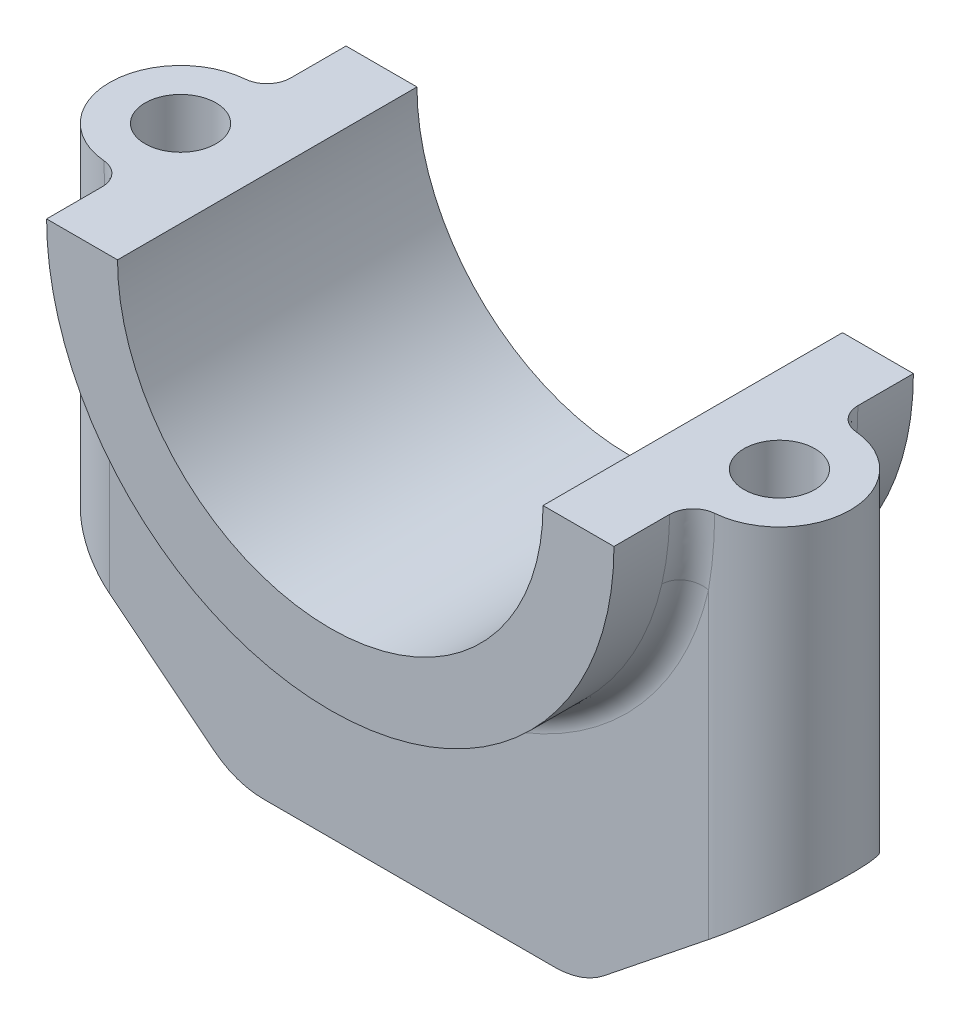
from build123d import *

# Parameters (mm, degrees)
BOSS_EXTRUDE3_DEPTH = 19
BOSS_EXTRUDE4_DEPTH = 60
CUT_EXTRUDE3_REACH  = 30
CUT_EXTRUDE4_REACH  = 62
SKETCH11_R          = 4.5
CUT_EXTRUDE5_DEPTH  = 23
FILLET2_R           = 10
FILLET3_R           = 3


with BuildPart() as part:
    # Sketch7 → Boss-Extrude3 (new body, symmetric)
    with BuildSketch(Plane.XY):
        with BuildLine():
            Line((-27, 0), (-36, 0))
            ThreePointArc((-36, 0), (0, -36), (36, 0))
            Line((36, 0), (27, 0))
            ThreePointArc((27, 0), (0, -27), (-27, 0))
        make_face()
    extrude(amount=BOSS_EXTRUDE3_DEPTH, both=True)

    # Sketch9 → Boss-Extrude4 (add)
    with BuildSketch(Plane(origin=(0, -60, 0), x_dir=(1, 0, 0), z_dir=(0, 1, 0))):
        with BuildLine():
            Line((-38, 9), (38, 9))
            ThreePointArc((38, 9), (47, 0), (38, -9))
            Line((38, -9), (-38, -9))
            ThreePointArc((-38, -9), (-47, 0), (-38, 9))
        make_face()
    extrude(amount=BOSS_EXTRUDE4_DEPTH)

    # Sketch10 → Cut-Extrude3 (cut, up to next)
    with BuildSketch(Plane.XY.offset(9), mode=Mode.PRIVATE) as cut_extrude3_sk1:
        with BuildLine():
            Line((27, 0), (-27, 0))
            ThreePointArc((-27, 0), (0, -27), (27, 0))
        make_face()
    cut_extrude3_tool1 = extrude(cut_extrude3_sk1.sketch, amount=-CUT_EXTRUDE3_REACH, mode=Mode.PRIVATE) & part.part
    add(cut_extrude3_tool1.solids().sort_by_distance((0, -11.459156, 9))[0], mode=Mode.SUBTRACT)

    # Sketch11 → Cut-Extrude4 (cut, up to next)
    with BuildSketch(Plane(origin=(0, 0, 0), x_dir=(1, 0, 0), z_dir=(0, 1, 0)), mode=Mode.PRIVATE) as cut_extrude4_sk1:
        with Locations((38, 0)):
            Circle(SKETCH11_R)
    cut_extrude4_tool1 = extrude(cut_extrude4_sk1.sketch, amount=-CUT_EXTRUDE4_REACH, mode=Mode.PRIVATE) & part.part
    add(cut_extrude4_tool1.solids().sort_by_distance((38, 0, 0))[0], mode=Mode.SUBTRACT)
    # Sketch11 → Cut-Extrude4 (cut, up to next)
    with BuildSketch(Plane(origin=(0, 0, 0), x_dir=(1, 0, 0), z_dir=(0, 1, 0)), mode=Mode.PRIVATE) as cut_extrude4_sk2:
        with Locations((-38, 0)):
            Circle(SKETCH11_R)
    cut_extrude4_tool2 = extrude(cut_extrude4_sk2.sketch, amount=-CUT_EXTRUDE4_REACH, mode=Mode.PRIVATE) & part.part
    add(cut_extrude4_tool2.solids().sort_by_distance((-38, 0, 0))[0], mode=Mode.SUBTRACT)

    # Sketch12 → Cut-Extrude5 (cut)
    with BuildSketch(Plane.XY.offset(14)):
        Polygon((-47, -40), (-47, -60), (-38, -60), (-38, -47.2), align=None)
        Polygon((-38, -47.2), (-38, -60), (-22, -60), align=None)
    cut_extrude5 = extrude(amount=-CUT_EXTRUDE5_DEPTH, mode=Mode.SUBTRACT)

    # Mirror1: Cut-Extrude5 across plane
    add(cut_extrude5.mirror(Plane(origin=(0, 0, 0), x_dir=(0, 0, 1), z_dir=(1, 0, 0))), mode=Mode.SUBTRACT)

    # Fillet2
    fillet2_edges = [part.edges().sort_by_distance(p)[0] for p in [
        (-22, -60, 0),
        (22, -60, 0),
    ]]
    fillet(fillet2_edges, radius=FILLET2_R)

    # Fillet3
    fillet3_edges = [part.edges().sort_by_distance(p)[0] for p in [
        (0, -36, -9),
        (0, -36, 9),
    ]]
    fillet(fillet3_edges, radius=FILLET3_R)


solid = part.part
